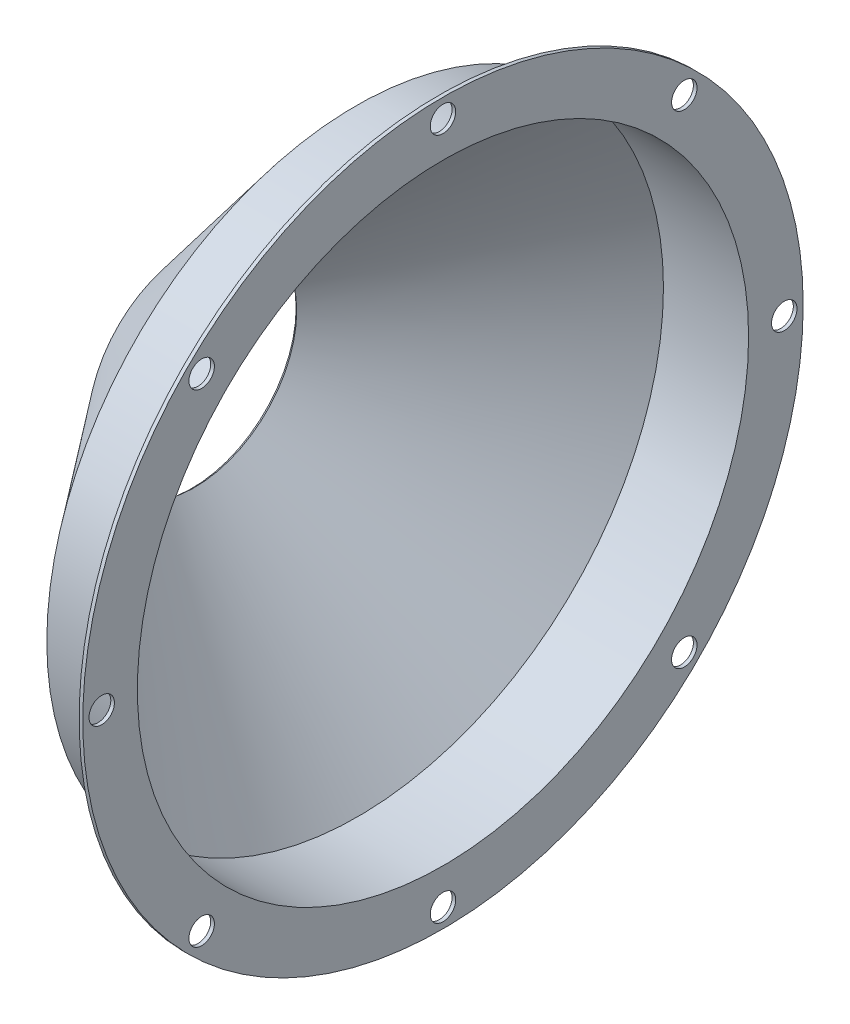
from build123d import *

# Parameters (mm, degrees)
SKETCH3_R          = 3.175
CUT_EXTRUDE1_DEPTH = 0.91186
CIRPATTERN1_COUNT  = 8


with BuildPart() as part:
    # Sketch1 → Revolve1 (revolve)
    with BuildSketch(Plane.XY):
        Polygon((-1101.212903226, 25.4), (-1060.572903226, 76.2), (-1040.252903226, 76.2), (-1039.341043226, 76.2), (-1039.341043226, 89.81186), (-1040.252903226, 89.81186), (-1040.252903226, 77.11186), (-1061.011165799, 77.11186), (-1101.924946258, 25.969634426), align=None)
    revolve(axis=Axis((0, 0, 0), (-1, 0, 0)))

    # Sketch3 → Cut-Extrude1 (cut)
    with BuildSketch(Plane.ZY.offset(1040.252903226)):
        with Locations((0, 85.09)):
            Circle(SKETCH3_R)
    cut_extrude1 = extrude(amount=-CUT_EXTRUDE1_DEPTH, mode=Mode.SUBTRACT)

    # CirPattern1: Cut-Extrude1 ×8 about axis
    cirpattern1_axis = Axis((0, 0, 0), (1, 0, 0))
    for i in range(1, CIRPATTERN1_COUNT):
        add(cut_extrude1.rotate(cirpattern1_axis, i * 360 / CIRPATTERN1_COUNT), mode=Mode.SUBTRACT)


solid = part.part
